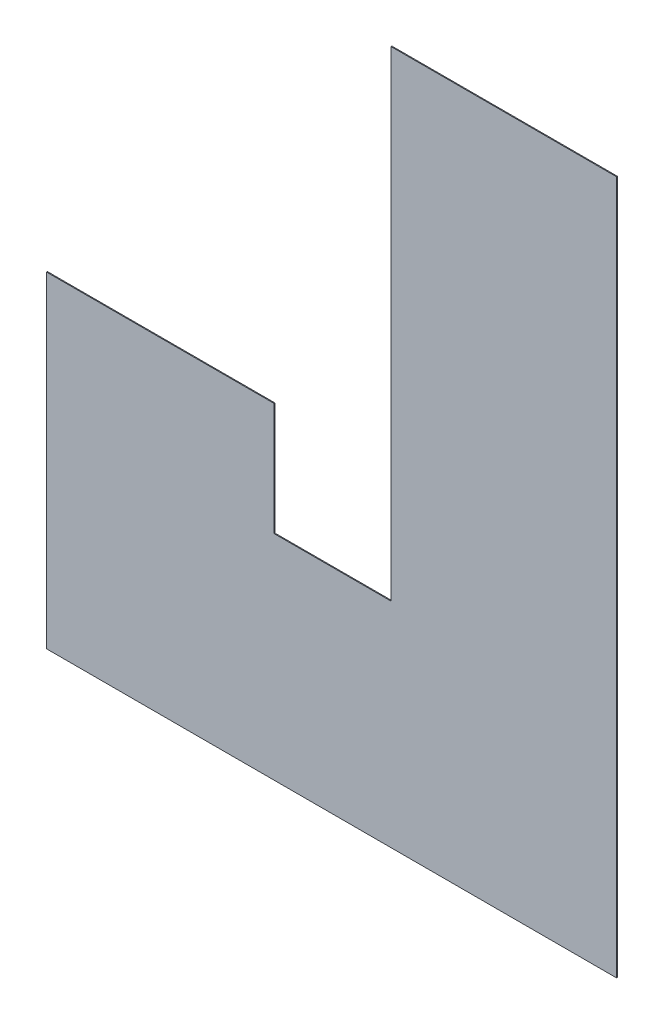
from build123d import *

# Parameters (mm, degrees)
SKETCH1_W           = 7610
SKETCH1_H           = 23390
BOSS_EXTRUDE1_DEPTH = 30


with BuildPart() as part:
    # Sketch1 → Boss-Extrude1 (new body)
    with BuildSketch(Plane.XY.offset(40625.220842973)):
        with Locations((-11801.617683291, -8387.518633414)):
            Rectangle(SKETCH1_W, SKETCH1_H)
        Polygon((-15606.617683291, -20082.518633414), (-15606.617683291, -12882.518633414), (-16246.617683291, -12882.518633414), (-19546.617683291, -12882.518633414), (-27221.617683291, -12882.518633414), (-27221.617683291, -20082.518633414), align=None)
        Polygon((-27221.617683291, -12882.518633414), (-19546.617683291, -12882.518633414), (-19546.617683291, -9107.518633414), (-19546.617683291, -9082.518633414), (-27221.617683291, -9082.518633414), align=None)
    extrude(amount=BOSS_EXTRUDE1_DEPTH)


solid = part.part
